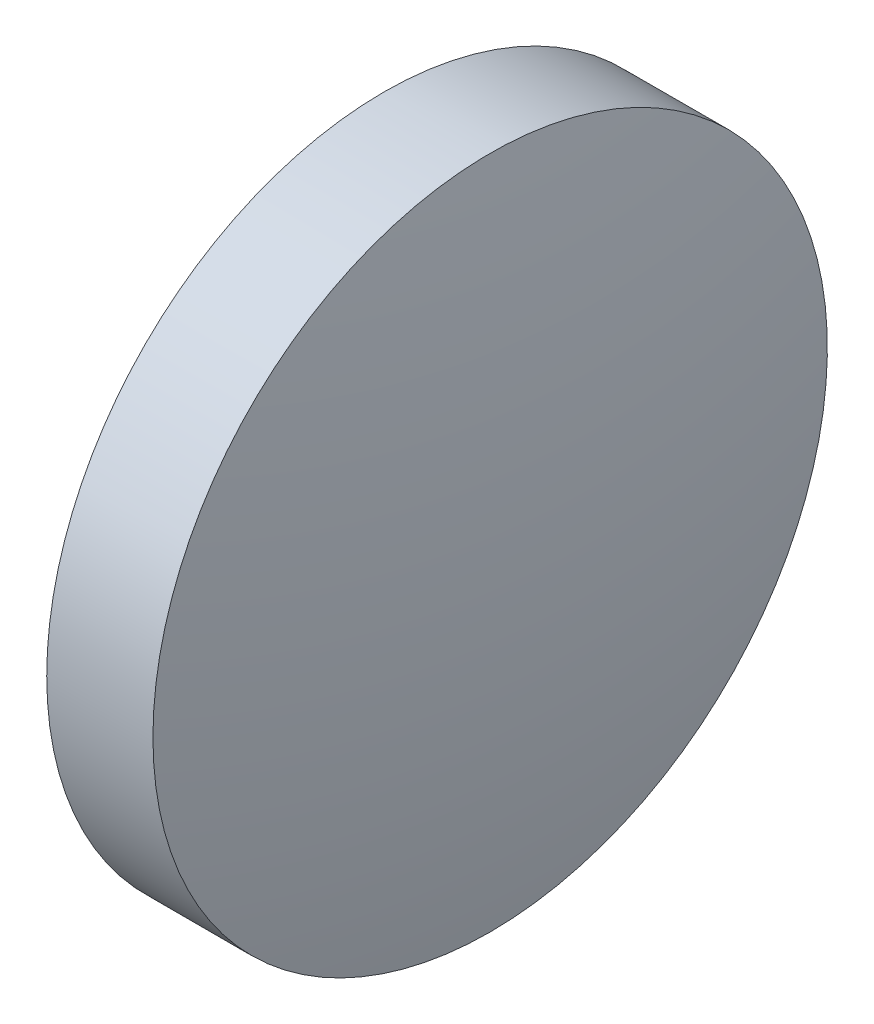
from build123d import *

# Parameters (mm, degrees)
SKETCH_1_ONE_SIDE_W = 2.000068571
SKETCH_1_ONE_SIDE_H = 6.35


with BuildPart() as part:
    # 草图1 one side → 旋转1 (revolve)
    with BuildSketch(Plane.XY, mode=Mode.PRIVATE) as revolve_1_sk:
        with Locations((43.229096888, 27.483056512)):
            Rectangle(SKETCH_1_ONE_SIDE_W, SKETCH_1_ONE_SIDE_H)
        with BuildLine():
            Line((41.629114602, 24.308056512), (42.229062602, 24.308056512))
            Line((42.229062602, 24.308056512), (42.229062602, 30.658056512))
            ThreePointArc((42.229062602, 30.658056512), (41.77943483, 27.4971958), (41.629114602, 24.308056512))
        make_face()
        with BuildLine():
            Line((44.229131173, 24.308056512), (44.829079173, 24.308056512))
            ThreePointArc((44.829079173, 24.308056512), (44.678758945, 27.4971958), (44.229131173, 30.658056512))
            Line((44.229131173, 30.658056512), (44.229131173, 24.308056512))
        make_face()
    revolve(revolve_1_sk.sketch.rotate(Axis((39.652700675, 24.308056512, 0), (1, 0, 0)), 90), axis=Axis((39.652700675, 24.308056512, 0), (1, 0, 0)))  # turned: the seam where the file's is


solid = part.part
